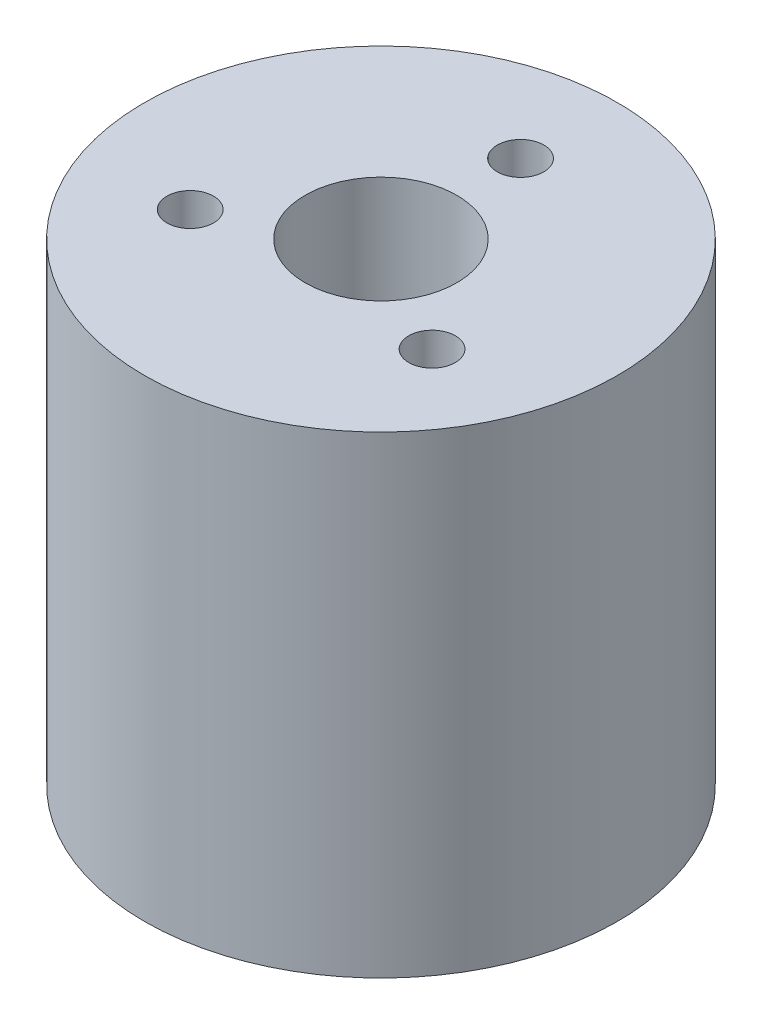
from build123d import *

# Parameters (mm, degrees)
SKETCH1_R           = 12.7
BOSS_EXTRUDE1_DEPTH = 25.4
SKETCH2_R           = 4.075
CUT_EXTRUDE1_DEPTH  = 19.05
SKETCH3_R           = 1.25
CUT_EXTRUDE2_DEPTH  = 10


with BuildPart() as part:
    # Sketch1 → Boss-Extrude1 (new body)
    with BuildSketch(Plane(origin=(0, 0, 0), x_dir=(1, 0, 0), z_dir=(0, 1, 0))):
        Circle(SKETCH1_R)
    extrude(amount=BOSS_EXTRUDE1_DEPTH)

    # Sketch2 → Cut-Extrude1 (cut)
    with BuildSketch(Plane(origin=(0, 25.4, 0), x_dir=(1, 0, 0), z_dir=(0, 1, 0))):
        Circle(SKETCH2_R)
    extrude(amount=-CUT_EXTRUDE1_DEPTH, mode=Mode.SUBTRACT)

    # Sketch3 → Cut-Extrude2 (cut)
    with BuildSketch(Plane(origin=(0, 25.4, 0), x_dir=(1, 0, 0), z_dir=(0, 1, 0))):
        with Locations((0, 7.5)):
            Circle(SKETCH3_R)
        with Locations((6.495190528, -3.75)):
            Circle(SKETCH3_R)
        with Locations((-6.495190528, -3.75)):
            Circle(SKETCH3_R)
    extrude(amount=-CUT_EXTRUDE2_DEPTH, mode=Mode.SUBTRACT)


solid = part.part
